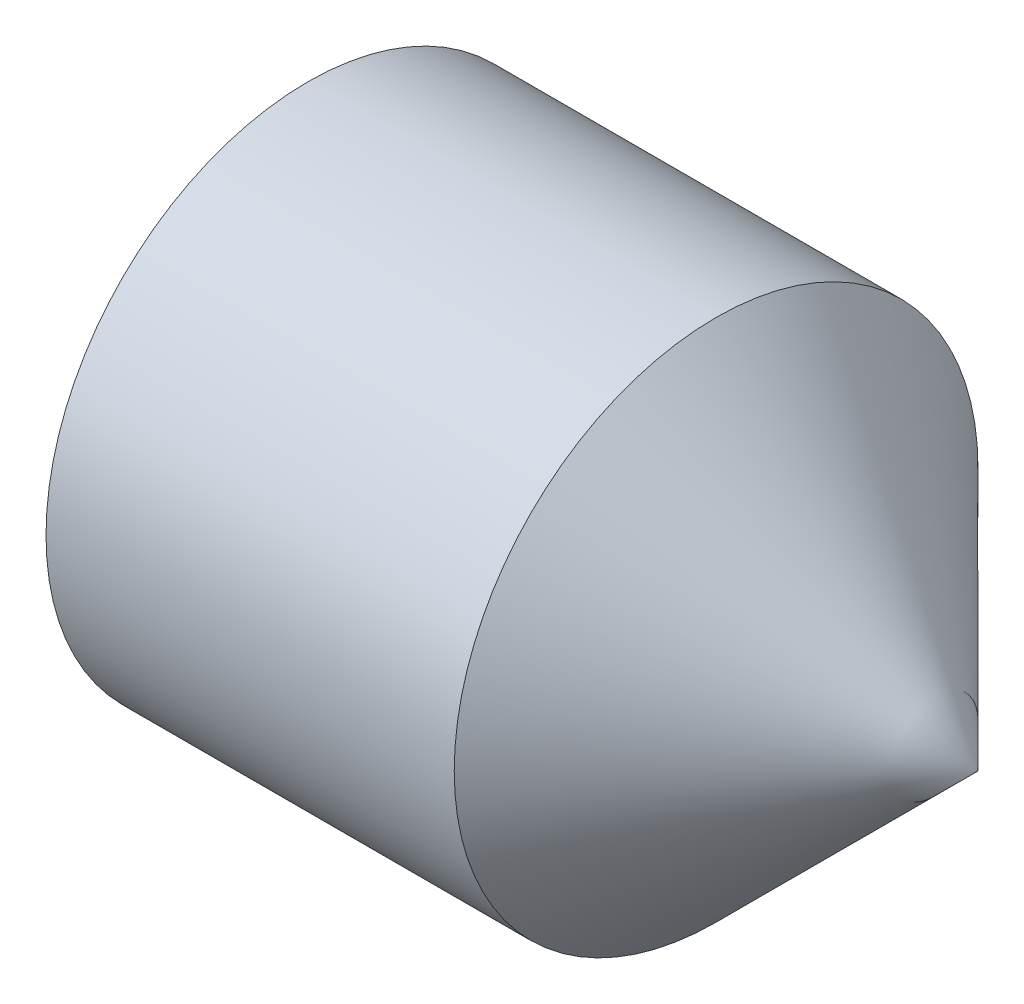
from build123d import *

# Parameters (mm, degrees)
HEX_2_DEPTH = 2


with BuildPart() as part:
    # BodySke → BaseBody (revolve)
    with BuildSketch(Plane.XY):
        Polygon((0, 0), (0, 1.2195), (0.161946751, 1.5), (2.5, 1.5), (4, 0), align=None)
    revolve(axis=Axis((-12.7, 0, 0), (1, 0, 0)))

    # Sketch2 → Hex 2 (cut)
    with BuildSketch(Plane.ZY):
        Polygon((0.433012702, 0.75), (-0.433012702, 0.75), (-0.866025404, 0), (-0.433012702, -0.75), (0.433012702, -0.75), (0.866025404, 0), align=None)
    extrude(amount=-HEX_2_DEPTH, mode=Mode.SUBTRACT)


solid = part.part
